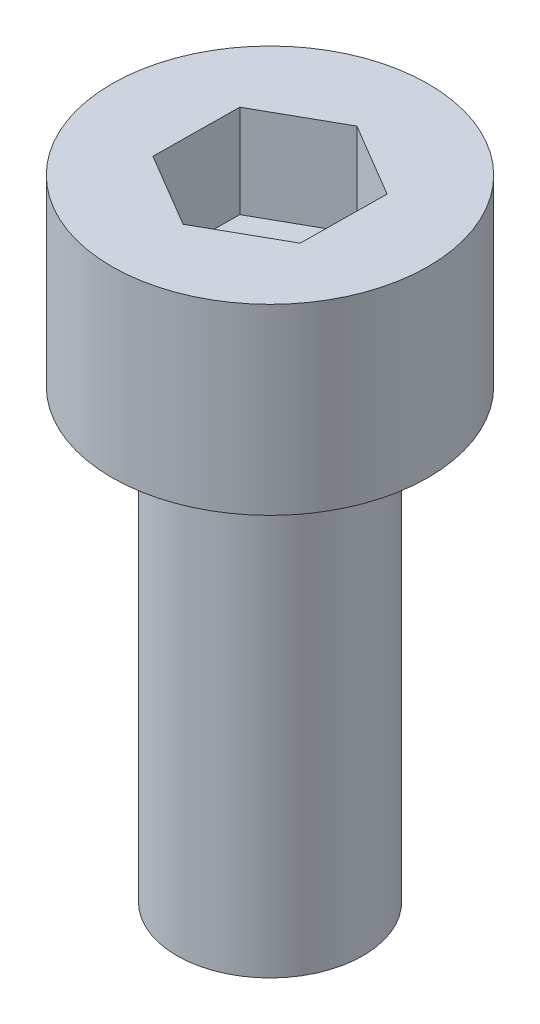
from build123d import *

# Parameters (mm, degrees)
SKETCH_1_R          = 2.5
EXTRUDE_1_DEPTH     = 12
SKETCH_2_R          = 4.25
EXTRUDE_2_DEPTH     = 4.91
CUT_EXTRUDE_1_DEPTH = 2.5


with BuildPart() as part:
    # 草图1 → 凸台-拉伸1 (new body)
    with BuildSketch(Plane(origin=(0, 0, 0), x_dir=(1, 0, 0), z_dir=(0, 1, 0))):
        Circle(SKETCH_1_R)
    extrude(amount=EXTRUDE_1_DEPTH)

    # 草图2 → 凸台-拉伸2 (add)
    with BuildSketch(Plane(origin=(0, 12, 0), x_dir=(1, 0, 0), z_dir=(0, 1, 0))):
        Circle(SKETCH_2_R)
    extrude(amount=EXTRUDE_2_DEPTH)

    # 草图3 → 切除-拉伸1 (cut)
    with BuildSketch(Plane(origin=(0, 16.91, 0), x_dir=(1, 0, 0), z_dir=(0, 1, 0))):
        Polygon((1.987239819, -1.176525067), (2.012520506, 1.132737633), (0.025280687, 2.309262701), (-1.987239819, 1.176525067), (-2.012520506, -1.132737633), (-0.025280687, -2.309262701), align=None)
    extrude(amount=-CUT_EXTRUDE_1_DEPTH, mode=Mode.SUBTRACT)


solid = part.part
